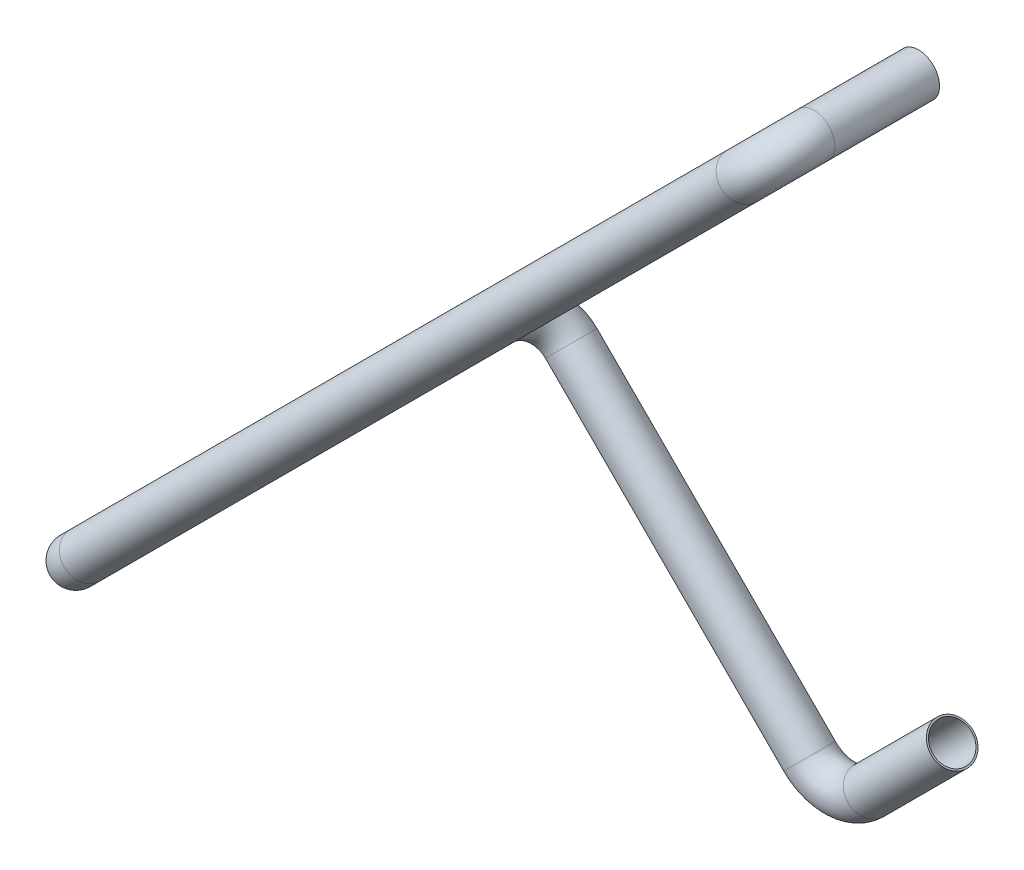
from build123d import *

# Parameters (mm, degrees)
PIPESKETCH_R   = 6.35
PIPESKETCH_R_2 = 5.842


with BuildPart() as part:
    # ThinSweep: sweep along a curve in space
    with BuildLine() as thinsweep_path:
        Line((0, 0, 0), (0, 0, 31.541945614))
        ThreePointArc((0, 0, 31.541945614), (-2.630256121, -2.630256121, 40.522201735), (-8.980256121, -8.980256121, 44.241945614))
        Line((-8.980256121, -8.980256121, 44.241945614), (-206.905101029, -206.905101029, 44.241945614))
        ThreePointArc((-206.905101029, -206.905101029, 44.241945614), (-213.255101029, -213.255101029, 40.522201735), (-215.885357151, -215.885357151, 31.541945614))
        Line((-215.885357151, -215.885357151, 31.541945614), (-215.885357151, -215.885357151, -89.5299))
        ThreePointArc((-215.885357151, -215.885357151, -89.5299), (-213.255101029, -218.515613272, -98.510156121), (-206.905101029, -224.865613272, -102.2299))
        Line((-206.905101029, -224.865613272, -102.2299), (-135.063052061, -296.70766224, -102.2299))
        ThreePointArc((-135.063052061, -296.70766224, -102.2299), (-126.08279594, -300.427406119, -102.2299), (-117.102539819, -296.70766224, -102.2299))
        Line((-92.070959765, -271.676082186, -102.2299), (-117.102539819, -296.70766224, -102.2299))
    # PipeSketch → ThinSweep (sweep)
    with BuildSketch(Plane.XY):
        Circle(PIPESKETCH_R)
        Circle(PIPESKETCH_R_2, mode=Mode.SUBTRACT)
    sweep(path=thinsweep_path.line)


solid = part.part
